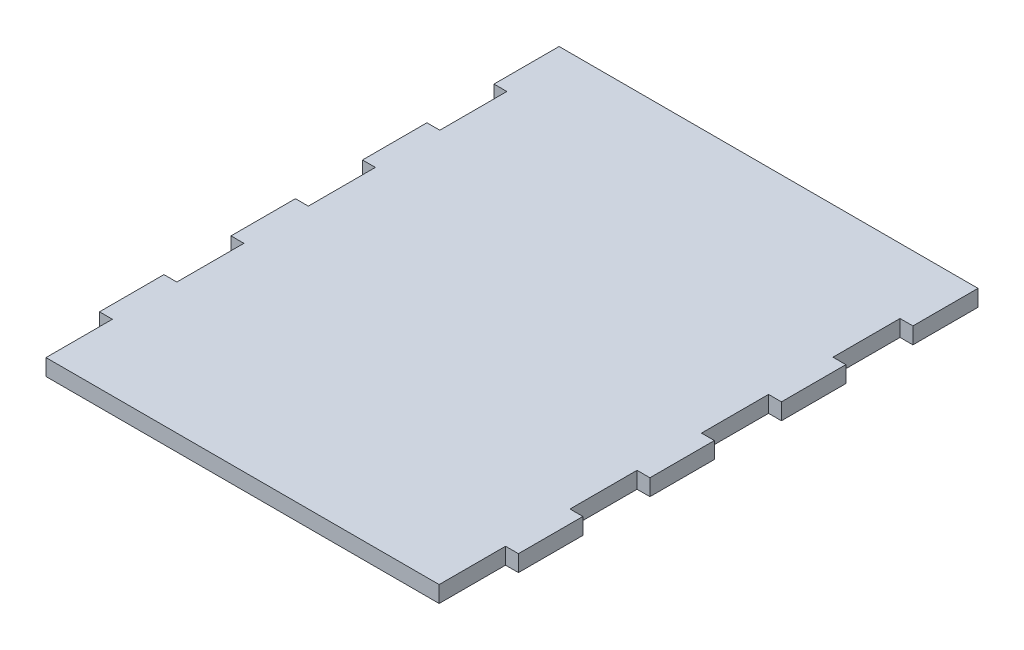
from build123d import *

# Parameters (mm, degrees)
BOSS_EXTRUDE1_DEPTH = 3.175
CUT_EXTRUDE1_DEPTH  = 4.175


with BuildPart() as part:
    # Sketch1 → Boss-Extrude1 (new body)
    with BuildSketch(Plane(origin=(0, 0, 0), x_dir=(1, 0, 0), z_dir=(0, 1, 0))):
        Polygon((0, 0), (76.2, 0), (76.2, 12.7), (78.6892, 12.7), (78.6892, 25.4), (76.2, 25.4), (76.2, 38.1), (78.6892, 38.1), (78.6892, 50.8), (76.2, 50.8), (76.2, 63.5), (78.6892, 63.5), (78.6892, 76.2), (76.2, 76.2), (76.2, 88.9), (78.6892, 88.9), (78.6892, 101.6), (-2.4892, 101.6), (-2.4892, 88.9), (0, 88.9), (0, 76.2), (-2.4892, 76.2), (-2.4892, 63.5), (0, 63.5), (0, 50.8), (-2.4892, 50.8), (-2.4892, 38.1), (0, 38.1), (0, 25.4), (-2.4892, 25.4), (-2.4892, 12.7), (0, 12.7), align=None)
    extrude(amount=BOSS_EXTRUDE1_DEPTH)

    # Sketch2 → Cut-Extrude1 (cut, through all)
    with BuildSketch(Plane(origin=(0, 3.175, 0), x_dir=(1, 0, 0), z_dir=(0, 1, 0))):
        Polygon((78.6892, 101.6), (78.5622, 101.6), (78.5622, 89.027), (76.073, 89.027), (76.073, 76.073), (78.5622, 76.073), (78.5622, 63.627), (76.073, 63.627), (76.073, 50.673), (78.5622, 50.673), (78.5622, 38.227), (76.073, 38.227), (76.073, 25.273), (78.5622, 25.273), (78.5622, 12.827), (76.073, 12.827), (76.073, 0), (76.2, 0), (76.2, 12.7), (78.6892, 12.7), (78.6892, 25.4), (76.2, 25.4), (76.2, 38.1), (78.6892, 38.1), (78.6892, 50.8), (76.2, 50.8), (76.2, 63.5), (78.6892, 63.5), (78.6892, 76.2), (76.2, 76.2), (76.2, 88.9), (78.6892, 88.9), align=None)
        Polygon((-2.3622, 101.6), (-2.4892, 101.6), (-2.4892, 88.9), (0, 88.9), (0, 76.2), (-2.4892, 76.2), (-2.4892, 63.5), (0, 63.5), (0, 50.8), (-2.4892, 50.8), (-2.4892, 38.1), (0, 38.1), (0, 25.4), (-2.4892, 25.4), (-2.4892, 12.7), (0, 12.7), (0, 0), (0.127, 0), (0.127, 12.827), (-2.3622, 12.827), (-2.3622, 25.273), (0.127, 25.273), (0.127, 38.227), (-2.3622, 38.227), (-2.3622, 50.673), (0.127, 50.673), (0.127, 63.627), (-2.3622, 63.627), (-2.3622, 76.073), (0.127, 76.073), (0.127, 89.027), (-2.3622, 89.027), align=None)
    extrude(amount=-CUT_EXTRUDE1_DEPTH, mode=Mode.SUBTRACT)


solid = part.part
